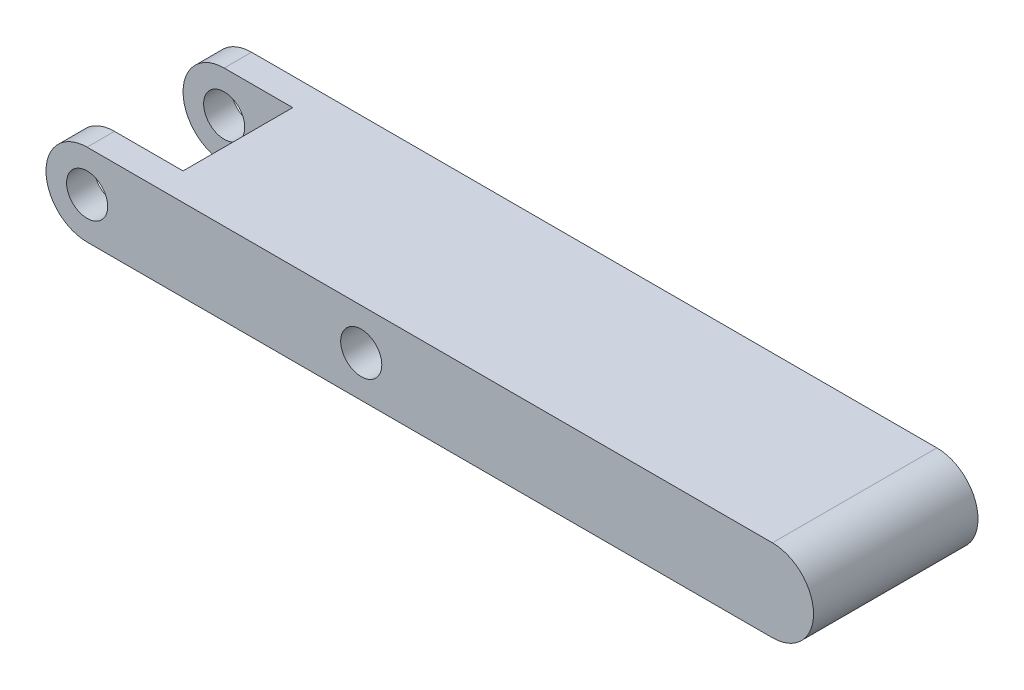
from build123d import *

# Parameters (mm, degrees)
SKETCH1_R           = 1.5
BOSS_EXTRUDE1_DEPTH = 12
SKETCH3_W           = 15.263515406
SKETCH3_H           = 8
CUT_EXTRUDE1_DEPTH  = 10


with BuildPart() as part:
    # Sketch1 → Boss-Extrude1 (new body)
    with BuildSketch(Plane.XY):
        with BuildLine():
            Line((-25, 3), (25, 3))
            ThreePointArc((25, 3), (28, 0), (25, -3))
            Line((25, -3), (-25, -3))
            ThreePointArc((-25, -3), (-28, 0), (-25, 3))
        make_face()
        with Locations((-25, 0)):
            Circle(SKETCH1_R, mode=Mode.SUBTRACT)
        with Locations((-5, 0)):
            Circle(SKETCH1_R, mode=Mode.SUBTRACT)
    extrude(amount=BOSS_EXTRUDE1_DEPTH)

    # Sketch3 → Cut-Extrude1 (cut)
    with BuildSketch(Plane(origin=(0, 3, 0), x_dir=(1, 0, 0), z_dir=(0, 1, 0))):
        with Locations((-27.631757703, -6)):
            Rectangle(SKETCH3_W, SKETCH3_H)
    extrude(amount=-CUT_EXTRUDE1_DEPTH, mode=Mode.SUBTRACT)


solid = part.part
